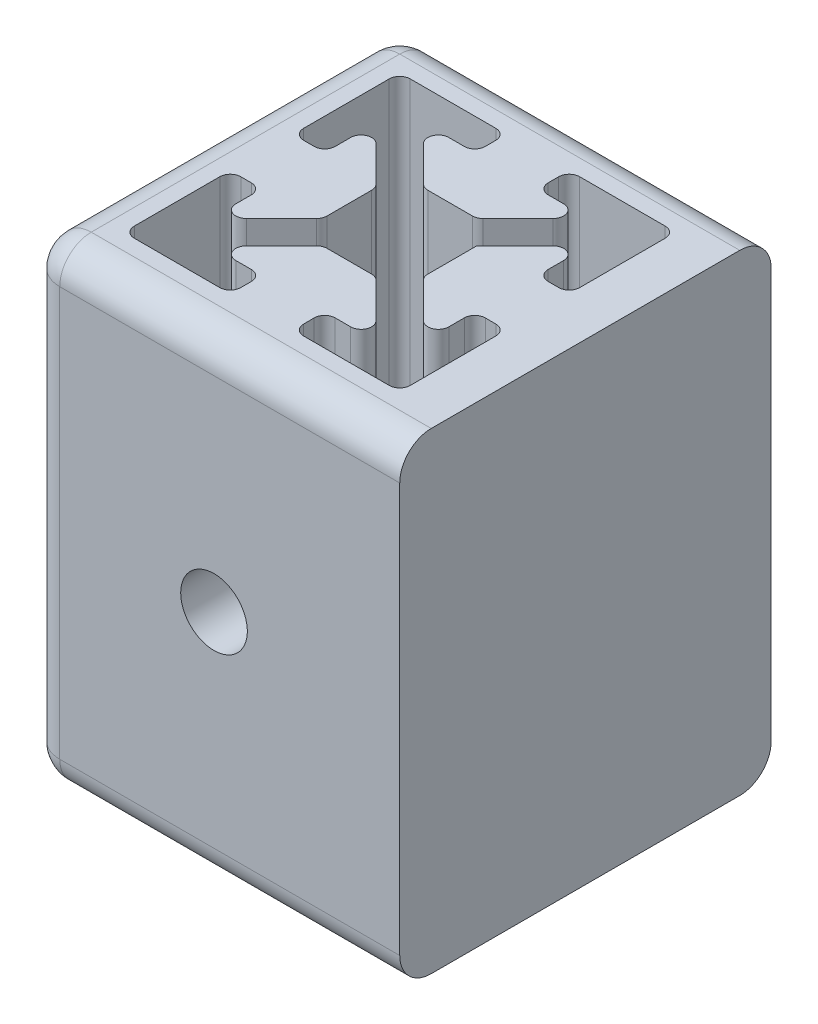
from build123d import *

# Parameters (mm, degrees)
SKETCH1_W           = 35.4
SKETCH1_H           = 35.4
BOSS_EXTRUDE1_DEPTH = 45
CUT_EXTRUDE1_DEPTH  = 45
FILLET1_R           = 1
SKETCH3_R           = 3.175
CUT_EXTRUDE2_DEPTH  = 35.4
SKETCH4_R           = 3.175
CUT_EXTRUDE3_DEPTH  = 12.9
FILLET2_R           = 3


with BuildPart() as part:
    # Sketch1 → Boss-Extrude1 (new body)
    with BuildSketch(Plane(origin=(0, 0, 0), x_dir=(1, 0, 0), z_dir=(0, 1, 0))):
        Rectangle(SKETCH1_W, SKETCH1_H)
    extrude(amount=BOSS_EXTRUDE1_DEPTH)

    # Sketch2 → Cut-Extrude1 (cut)
    with BuildSketch(Plane(origin=(0, 45, 0), x_dir=(1, 0, 0), z_dir=(0, 1, 0))):
        Polygon((-4.8, 2.5372583), (-10.15, 7.8872583), (-10.15, 3), (-13.15, 3), (-13.15, 13.15), (-3, 13.15), (-3, 10.15), (-7.8872583, 10.15), (-2.5372583, 4.8), (2.5372583, 4.8), (7.8872583, 10.15), (3, 10.15), (3, 13.15), (13.15, 13.15), (13.15, 3), (10.15, 3), (10.15, 7.8872583), (4.8, 2.5372583), (4.8, -2.5372583), (10.15, -7.8872583), (10.15, -3), (13.15, -3), (13.15, -13.15), (3, -13.15), (3, -10.15), (7.8872583, -10.15), (2.5372583, -4.8), (-2.5372583, -4.8), (-7.8872583, -10.15), (-3, -10.15), (-3, -13.15), (-13.15, -13.15), (-13.15, -3), (-10.15, -3), (-10.15, -7.8872583), (-4.8, -2.5372583), align=None)
    extrude(amount=-CUT_EXTRUDE1_DEPTH, mode=Mode.SUBTRACT)

    # Fillet1
    fillet1_edges = [part.edges().sort_by_distance(p)[0] for p in [
        (-13.15, 22.5, -3),
        (-10.15, 22.5, -3),
        (-10.15, 22.5, -7.8872583),
        (-4.8, 22.5, -2.5372583),
        (-4.8, 22.5, 2.5372583),
        (-10.15, 22.5, 7.8872583),
        (-10.15, 22.5, 3),
        (-13.15, 22.5, 3),
        (-13.15, 22.5, 13.15),
        (-3, 22.5, 13.15),
        (-3, 22.5, 10.15),
        (-7.8872583, 22.5, 10.15),
        (-2.5372583, 22.5, 4.8),
        (2.5372583, 22.5, 4.8),
        (7.8872583, 22.5, 10.15),
        (3, 22.5, 10.15),
        (3, 22.5, 13.15),
        (13.15, 22.5, 13.15),
        (13.15, 22.5, 3),
        (10.15, 22.5, 3),
        (10.15, 22.5, 7.8872583),
        (4.8, 22.5, 2.5372583),
        (10.15, 22.5, -7.8872583),
        (10.15, 22.5, -3),
        (13.15, 22.5, -3),
        (13.15, 22.5, -13.15),
        (3, 22.5, -13.15),
        (3, 22.5, -10.15),
        (7.8872583, 22.5, -10.15),
        (2.5372583, 22.5, -4.8),
        (-2.5372583, 22.5, -4.8),
        (-7.8872583, 22.5, -10.15),
        (-3, 22.5, -10.15),
        (-3, 22.5, -13.15),
        (-13.15, 22.5, -13.15),
    ]]
    fillet(fillet1_edges, radius=FILLET1_R)

    # Sketch3 → Cut-Extrude2 (cut)
    with BuildSketch(Plane(origin=(0, 0, -17.7), x_dir=(-1, 0, 0), z_dir=(0, 0, -1))):
        with Locations((0, 22.5)):
            Circle(SKETCH3_R)
    extrude(amount=-CUT_EXTRUDE2_DEPTH, mode=Mode.SUBTRACT)

    # Sketch4 → Cut-Extrude3 (cut)
    with BuildSketch(Plane.ZY.offset(17.7)):
        with Locations((0, 22.5)):
            Circle(SKETCH4_R)
    extrude(amount=-CUT_EXTRUDE3_DEPTH, mode=Mode.SUBTRACT)

    # Fillet2
    fillet2_edges = [part.edges().sort_by_distance(p)[0] for p in [
        (-17.7, 22.5, 17.7),
        (0, 45, 17.7),
        (-17.7, 22.5, -17.7),
        (-17.7, 45, 0),
        (0, 45, -17.7),
        (0, 0, 17.7),
        (-17.7, 0, 0),
        (0, 0, -17.7),
    ]]
    fillet(fillet2_edges, radius=FILLET2_R)


solid = part.part
